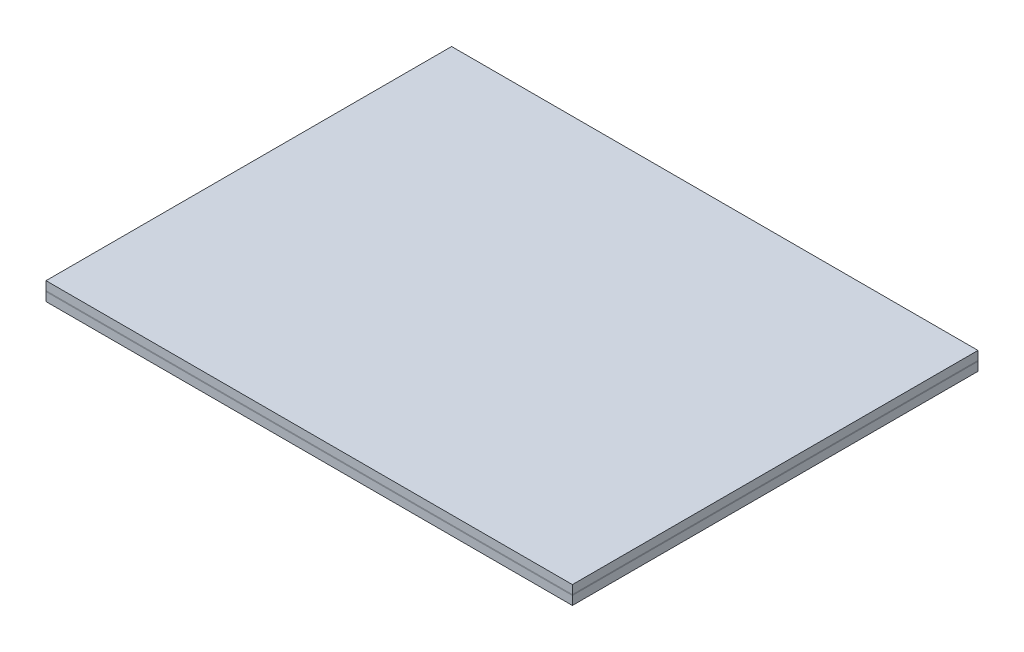
from build123d import *

# Parameters (mm, degrees)
SKETCH1_W           = 61
SKETCH1_H           = 47
BOSS_EXTRUDE1_DEPTH = 1
SKETCH2_W           = 61
SKETCH2_H           = 47
SKETCH2_W_2         = 57
SKETCH2_H_2         = 44
BOSS_EXTRUDE5_DEPTH = 0.1
BOSS_EXTRUDE3_START = 1.1
SKETCH1_3_W         = 61
SKETCH1_3_H         = 47
BOSS_EXTRUDE3_DEPTH = 1


with BuildPart() as part:
    # Sketch1 → Boss-Extrude1 (new body)
    with BuildSketch(Plane(origin=(0, 0, 0), x_dir=(1, 0, 0), z_dir=(0, 1, 0))):
        with Locations((2.931492843, -8.40593047)):
            Rectangle(SKETCH1_W, SKETCH1_H)
    extrude(amount=BOSS_EXTRUDE1_DEPTH)


with BuildPart() as body_2:
    # Sketch2 → Boss-Extrude5 (new body)
    with BuildSketch(Plane(origin=(0, 1, 0), x_dir=(1, 0, 0), z_dir=(0, 1, 0))):
        with Locations((2.931492843, -8.40593047)):
            Rectangle(SKETCH2_W, SKETCH2_H)
        with Locations((3.431492843, -8.40593047)):
            Rectangle(SKETCH2_W_2, SKETCH2_H_2, mode=Mode.SUBTRACT)
    extrude(amount=BOSS_EXTRUDE5_DEPTH)


with BuildPart() as body_3:
    # Sketch1_3 → Boss-Extrude3 (new body)
    with BuildSketch(Plane(origin=(0, 0, 0), x_dir=(1, 0, 0), z_dir=(0, 1, 0)).offset(BOSS_EXTRUDE3_START)):
        with Locations((2.931492843, -8.40593047)):
            Rectangle(SKETCH1_3_W, SKETCH1_3_H)
    extrude(amount=BOSS_EXTRUDE3_DEPTH)


solid = Compound([part.part, body_2.part, body_3.part])
